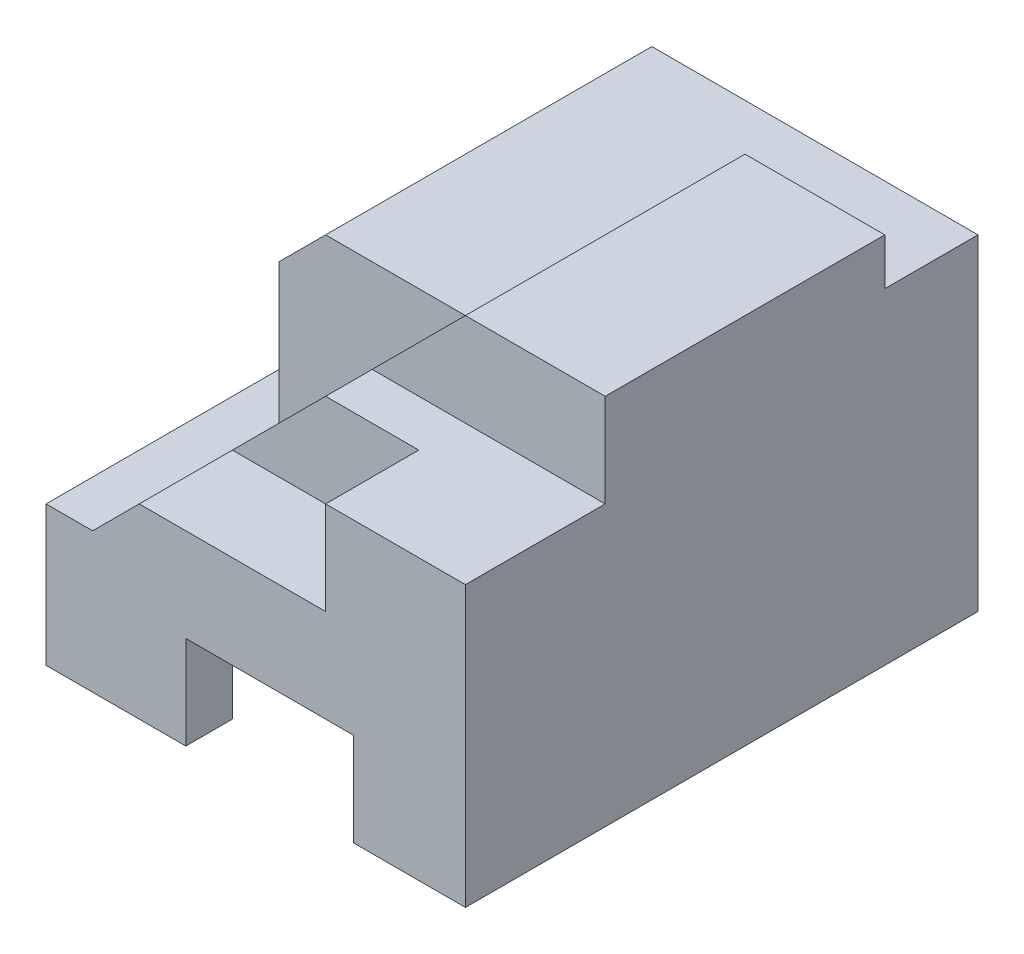
from build123d import *

# Parameters (mm, degrees)
SKETCH1_W           = 10
SKETCH1_H           = 8
BOSS_EXTRUDE1_DEPTH = 11
SKETCH2_W           = 2
SKETCH2_H           = 1
SKETCH2_W_2         = 3
SKETCH2_H_2         = 2
CUT_EXTRUDE1_DEPTH  = 11
SKETCH3_W           = 4
SKETCH3_H           = 2
CUT_EXTRUDE2_DEPTH  = 2
CUT_EXTRUDE3_DEPTH  = 4
SKETCH5_W           = 2
SKETCH5_H           = 1
CUT_EXTRUDE4_DEPTH  = 5
SKETCH6_W           = 2
SKETCH6_H           = 5
CUT_EXTRUDE5_DEPTH  = 9
CUT_EXTRUDE6_DEPTH  = 7
CUT_EXTRUDE7_DEPTH  = 7
CUT_EXTRUDE8_DEPTH  = 2


with BuildPart() as part:
    # Sketch1 → Boss-Extrude1 (new body)
    with BuildSketch(Plane.XY):
        with Locations((5, 4)):
            Rectangle(SKETCH1_W, SKETCH1_H)
    extrude(amount=BOSS_EXTRUDE1_DEPTH)

    # Sketch2 → Cut-Extrude1 (cut)
    with BuildSketch(Plane.ZY):
        with Locations((1, 7.5)):
            Rectangle(SKETCH2_W, SKETCH2_H)
        with Locations((9.5, 7)):
            Rectangle(SKETCH2_W_2, SKETCH2_H_2)
    extrude(amount=-CUT_EXTRUDE1_DEPTH, mode=Mode.SUBTRACT)

    # Sketch3 → Cut-Extrude2 (cut)
    with BuildSketch(Plane.XY.offset(11)):
        with Locations((5, 5)):
            Rectangle(SKETCH3_W, SKETCH3_H)
    extrude(amount=-CUT_EXTRUDE2_DEPTH, mode=Mode.SUBTRACT)

    # Sketch4 → Cut-Extrude3 (cut)
    with BuildSketch(Plane.XY.offset(11)):
        Polygon((3, 4), (2, 3), (2, 8), (7, 8), align=None)
    extrude(amount=-CUT_EXTRUDE3_DEPTH, mode=Mode.SUBTRACT)

    # Sketch5 → Cut-Extrude4 (cut)
    with BuildSketch(Plane.XY.offset(7)):
        Polygon((6, 7), (7, 8), (2, 8), (2, 7), align=None)
        with Locations((1, 7.5)):
            Rectangle(SKETCH5_W, SKETCH5_H)
    extrude(amount=-CUT_EXTRUDE4_DEPTH, mode=Mode.SUBTRACT)

    # Sketch6 → Cut-Extrude5 (cut)
    with BuildSketch(Plane.XY.offset(11)):
        with Locations((1, 5.5)):
            Rectangle(SKETCH6_W, SKETCH6_H)
    extrude(amount=-CUT_EXTRUDE5_DEPTH, mode=Mode.SUBTRACT)

    # Sketch7 → Cut-Extrude6 (cut)
    with BuildSketch(Plane.XY.offset(7)):
        Polygon((3, 7), (0, 4), (0, 7), align=None)
    extrude(amount=-CUT_EXTRUDE6_DEPTH, mode=Mode.SUBTRACT)

    # Sketch9 → Cut-Extrude7 (cut)
    with BuildSketch(Plane(origin=(0, 3, 0), x_dir=(1, 0, 0), z_dir=(0, 1, 0))):
        Polygon((0, -2), (1, -3), (1, -11), (0, -11), align=None)
    extrude(amount=-CUT_EXTRUDE7_DEPTH, mode=Mode.SUBTRACT)

    # Sketch10 → Cut-Extrude8 (cut)
    with BuildSketch(Plane.XZ):
        Polygon((1, 3), (2, 4), (7.595103791, 4), (7.595103791, 9.328283849), (7.595103791, 11), (4, 11), (4, 10), (1, 10), (1, 4.286480229), align=None)
    extrude(amount=-CUT_EXTRUDE8_DEPTH, mode=Mode.SUBTRACT)


solid = part.part
